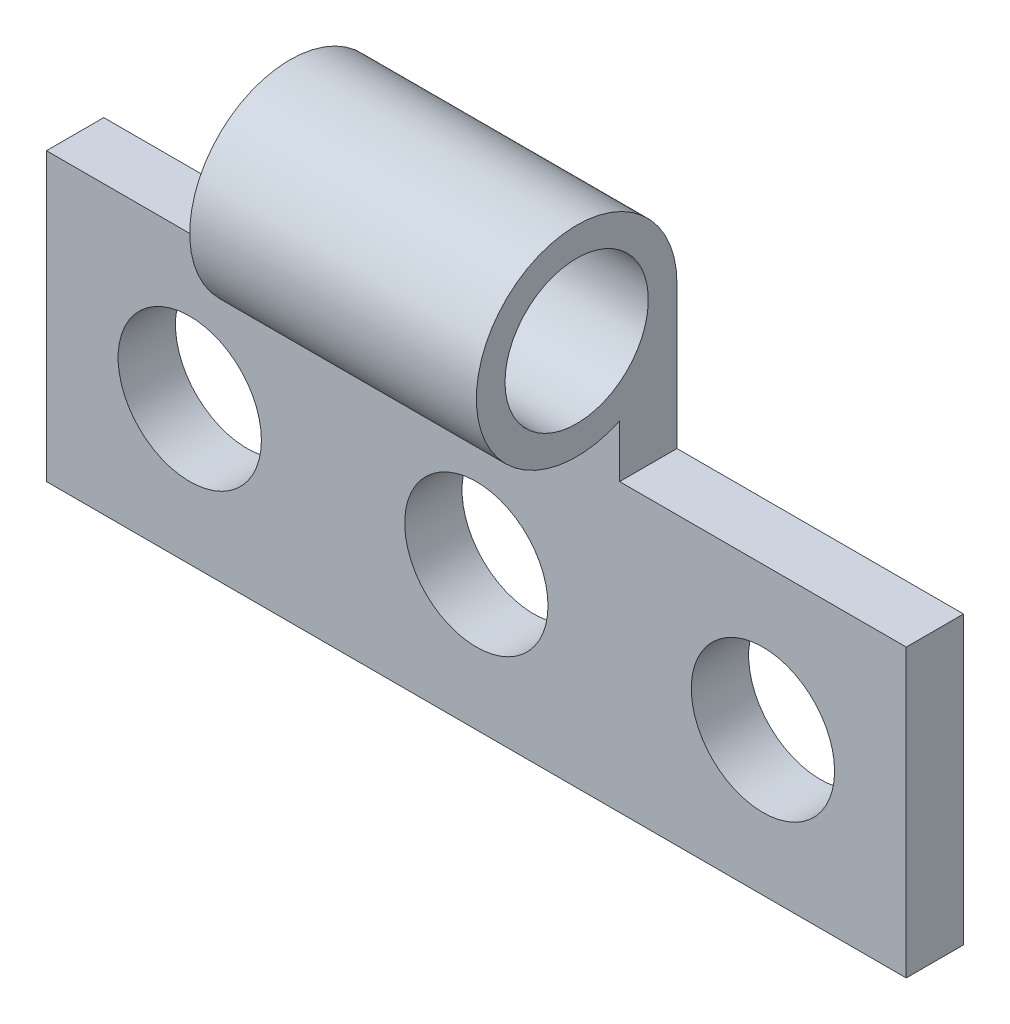
from build123d import *

# Parameters (mm, degrees)
SKETCH1_W                = 30
SKETCH1_H                = 10
BOSS_EXTRUDE1_DEPTH      = 2
SKETCH2_R                = 2.5
BOSS_EXTRUDE2_DEPTH      = 5
BOSS_EXTRUDE2_DEPTH_BACK = 5
SKETCH3_R                = 2.5
CUT_EXTRUDE1_DEPTH       = 10


with BuildPart() as part:
    # Sketch1 → Boss-Extrude1 (new body)
    with BuildSketch(Plane.XY):
        Rectangle(SKETCH1_W, SKETCH1_H)
    extrude(amount=BOSS_EXTRUDE1_DEPTH)

    # Sketch2 → Boss-Extrude2 (add, two sides)
    with BuildSketch(Plane.ZY) as boss_extrude2_sk:
        with BuildLine():
            Line((0, 5), (0, 10))
            ThreePointArc((0, 10), (6.458039892, 11.870828693), (2, 6.83772234))
            Line((2, 6.83772234), (2, 5))
            Line((2, 5), (0, 5))
        make_face()
        with Locations((3.5, 10)):
            Circle(SKETCH2_R, mode=Mode.SUBTRACT)
    extrude(amount=BOSS_EXTRUDE2_DEPTH)
    extrude(boss_extrude2_sk.sketch, amount=-BOSS_EXTRUDE2_DEPTH_BACK)

    # Sketch3 → Cut-Extrude1 (cut)
    with BuildSketch(Plane.XY.offset(2)):
        with Locations((-10, 0)):
            Circle(SKETCH3_R)
        Circle(SKETCH3_R)
        with Locations((10, 0)):
            Circle(SKETCH3_R)
    extrude(amount=-CUT_EXTRUDE1_DEPTH, mode=Mode.SUBTRACT)


solid = part.part
